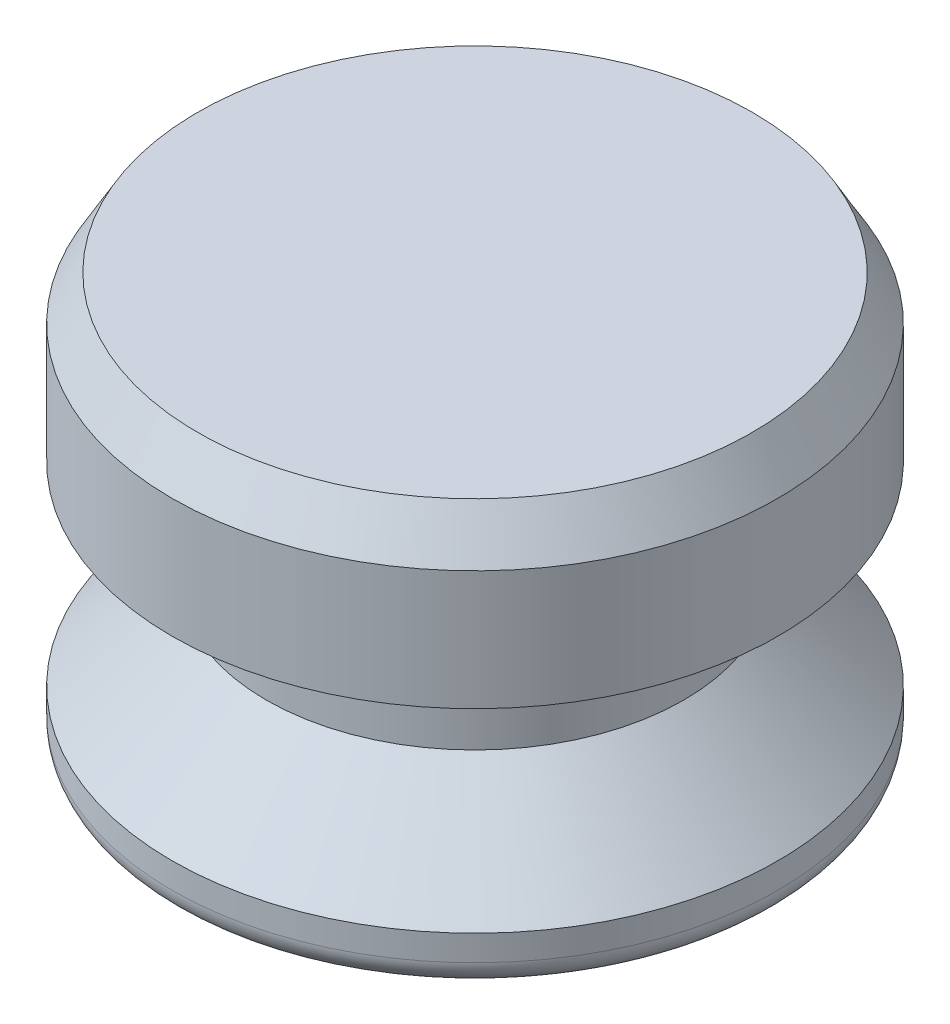
from build123d import *

# Parameters (mm, degrees)
FILLET1_R      = 0.79375
CHAMFER1_SIZE  = 0.79375
CHAMFER1_SIZE2 = 1.374815329


with BuildPart() as part:
    # Sketch1 → Revolve1 (revolve)
    with BuildSketch(Plane.XY):
        Polygon((0, 0), (-9.398, 0), (-9.398, 1.5875), (-6.477, 4.445), (-6.477, 7.62), (-9.398, 7.62), (-9.398, 12.7), (0, 12.7), align=None)
    revolve(axis=Axis((0, 0, 0), (0, 1, 0)))

    # Fillet1
    fillet1_edges = [part.edges().sort_by_distance(p)[0] for p in [
        (9.398, 0, 0),
    ]]
    fillet(fillet1_edges, radius=FILLET1_R)

    # Chamfer1
    chamfer1_edges = [part.edges().sort_by_distance(p)[0] for p in [
        (9.398, 12.7, 0),
    ]]
    chamfer1_side = [part.faces().sort_by_distance(p)[0] for p in [
        (0, 12.7, 0),
    ]]
    chamfer(chamfer1_edges, length=CHAMFER1_SIZE, length2=CHAMFER1_SIZE2, reference=chamfer1_side[0])


solid = part.part
